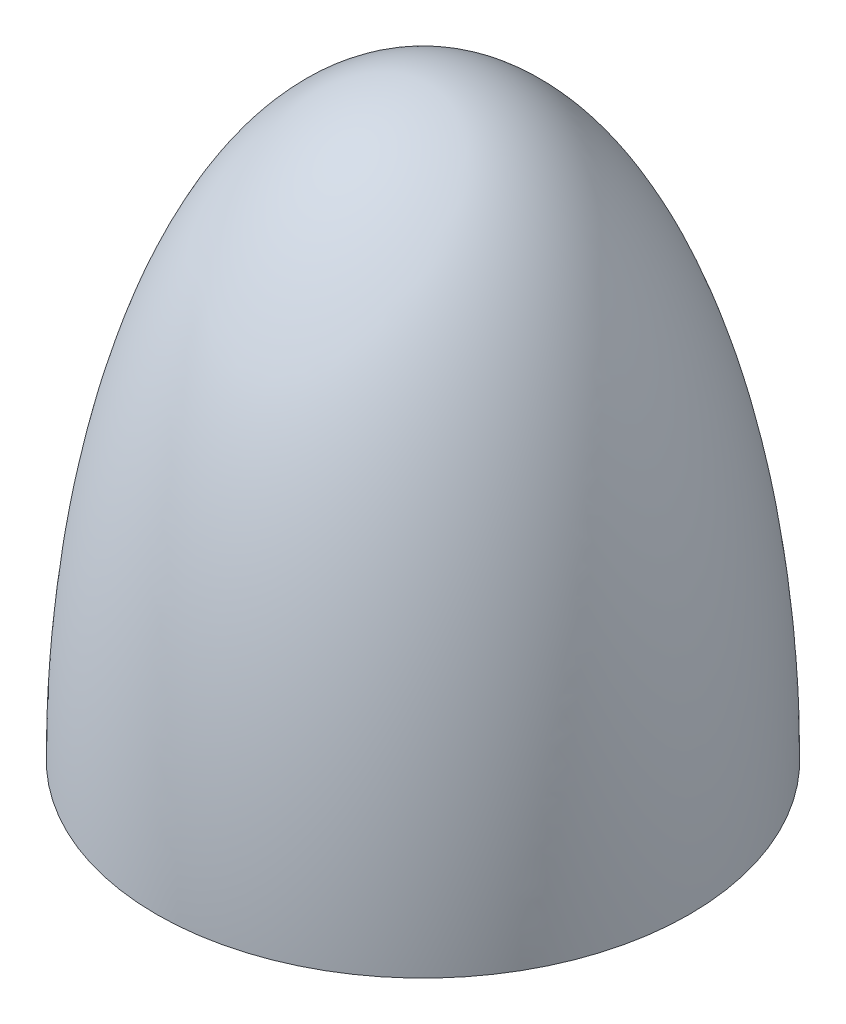
from build123d import *


with BuildPart() as part:
    # Sketch1 → Revolve1 (revolve)
    with BuildSketch(Plane.XY):
        with BuildLine():
            Line((0, 20), (0, 22))
            add(Edge.make_bspline(
                [(10, 0), (10, 0.680678408), (9.946524655, 3.403392041), (9.411771204, 8.754599213), (8.009994319, 14.039528033), (6.209928282, 17.750123489), (4.563757399, 19.972349981), (2.535938929, 21.561905969), (0.845312976, 22), (0, 22)],
                knots=[4.71238898, 4.71238898, 4.71238898, 4.71238898, 4.810563751, 5.105088062, 5.497787144, 5.694136685, 5.890486225, 6.086835766, 6.283185307, 6.283185307, 6.283185307, 6.283185307], degree=3))
            Line((10, 0), (8, 0))
            add(Edge.make_bspline(
                [(8, 0), (8, 20), (0, 20)],
                knots=[4.71238898, 4.71238898, 4.71238898, 6.283185307, 6.283185307, 6.283185307], degree=2, weights=[1, 0.707106781, 1]))
        make_face()
    revolve(axis=Axis((0, 20, 0), (0, 1, 0)))


solid = part.part
